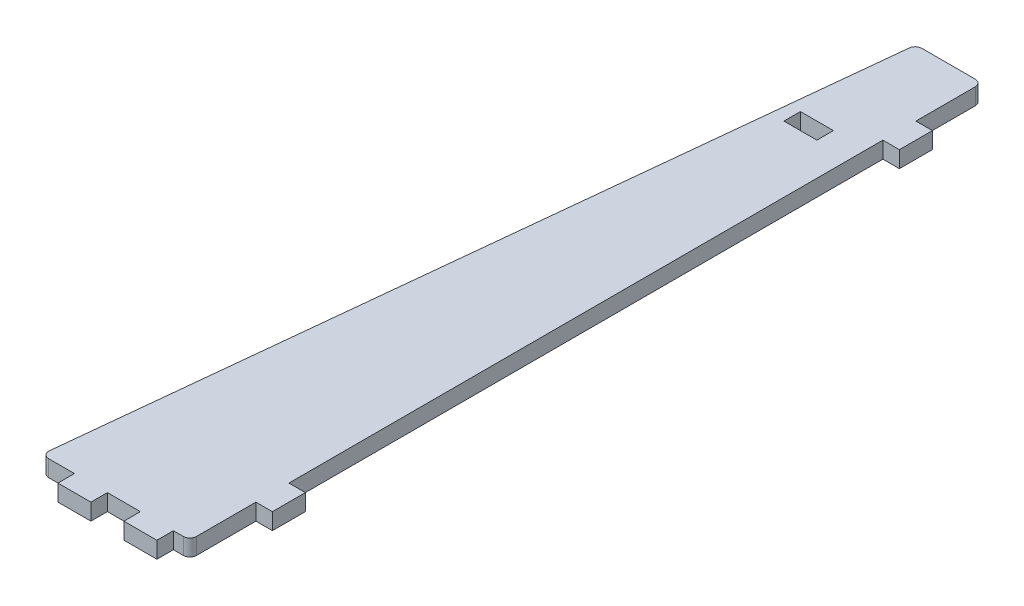
from build123d import *

# Parameters (mm, degrees)
SKETCH1_W           = 12.7
SKETCH1_H           = 6.35
BOSS_EXTRUDE1_DEPTH = 6.35
FILLET1_R           = 2.54


with BuildPart() as part:
    # Sketch1 → Boss-Extrude1 (new body)
    with BuildSketch(Plane(origin=(0, 0, 0), x_dir=(1, 0, 0), z_dir=(0, 1, 0))):
        Polygon((0, 0), (12.7, 0), (12.7, -6.35), (25.4, -6.35), (25.4, 0), (38.1, 0), (38.1, -6.35), (50.8, -6.35), (50.8, 0), (57.15, 0), (57.15, 25.4), (63.5, 25.4), (63.5, 38.1), (57.15, 38.1), (57.15, 266.7), (63.5, 266.7), (63.5, 279.4), (57.15, 279.4), (57.15, 304.8), (31.75, 304.8), align=None)
        with Locations((38.1, 257.175)):
            Rectangle(SKETCH1_W, SKETCH1_H, mode=Mode.SUBTRACT)
    extrude(amount=BOSS_EXTRUDE1_DEPTH)

    # Fillet1
    fillet1_edges = [part.edges().sort_by_distance(p)[0] for p in [
        (31.75, 3.175, -304.8),
        (57.15, 3.175, -304.8),
        (57.15, 3.175, 0),
        (0, 3.175, 0),
    ]]
    fillet(fillet1_edges, radius=FILLET1_R)


solid = part.part
